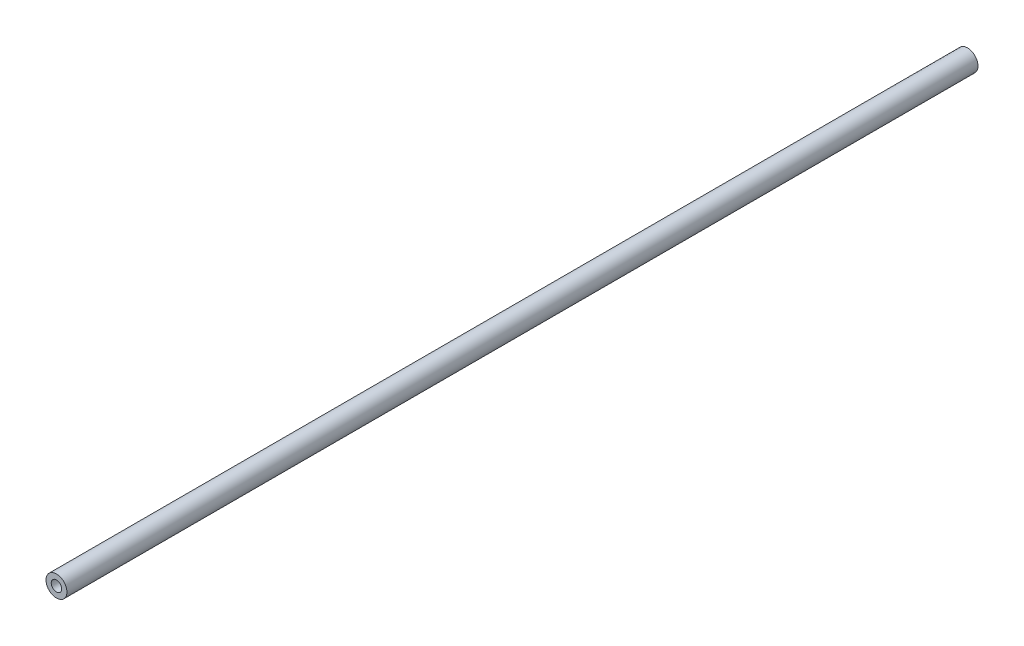
from build123d import *

# Parameters (mm, degrees)
ESQUISSE1_R        = 12.7
ESQUISSE1_R_2      = 6.35
BOSS_EXTRU_1_DEPTH = 1104.9


with BuildPart() as part:
    # Esquisse1 → Boss.-Extru.1 (new body)
    with BuildSketch(Plane.XY):
        Circle(ESQUISSE1_R)
        Circle(ESQUISSE1_R_2, mode=Mode.SUBTRACT)
    extrude(amount=BOSS_EXTRU_1_DEPTH)


solid = part.part
